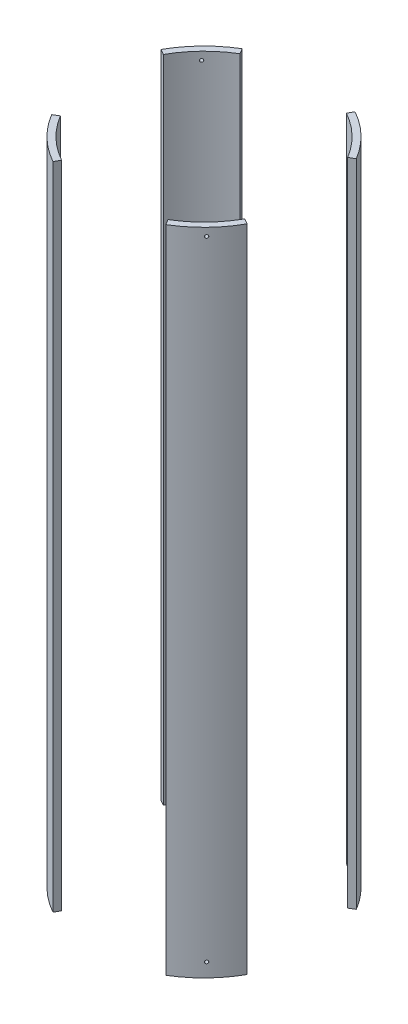
from build123d import *

# Parameters (mm, degrees)
SKETCH2_R               = 88.9
SKETCH2_R_2             = 83.82
BOSS_EXTRUDE1_DEPTH     = 260.20776
CUT_EXTRUDE1_DEPTH      = 261.20776
CUT_EXTRUDE1_DEPTH_BACK = 261.20776
SKETCH5_R               = 1.27
BOLT_HOLES_DEPTH        = 29.911624556
BOLT_PATTERN_COUNT      = 4


with BuildPart() as part:
    # Sketch2 → Boss-Extrude1 (new body, symmetric)
    with BuildSketch(Plane(origin=(0, 0, 0), x_dir=(1, 0, 0), z_dir=(0, 1, 0))):
        Circle(SKETCH2_R)
        Circle(SKETCH2_R_2, mode=Mode.SUBTRACT)
    extrude(amount=BOSS_EXTRUDE1_DEPTH, both=True)

    # Sketch3 → Cut-Extrude1 (cut, two sides)
    with BuildSketch(Plane(origin=(0, 0, 0), x_dir=(1, 0, 0), z_dir=(0, 1, 0))) as cut_extrude1_sk:
        Polygon((169.661755759, -94.300371224), (0, 0), (169.661755759, 101.677593364), align=None)
        Polygon((0, 0), (53.900027233, 96.974944394), (-58.116685864, 96.974944394), align=None)
        Polygon((-123.741299607, 68.777140945), (-123.741299607, -74.157652604), (0, 0), align=None)
        Polygon((-65.840936026, -118.45858783), (0, 0), (70.991745134, -118.45858783), align=None)
    extrude(amount=CUT_EXTRUDE1_DEPTH, mode=Mode.SUBTRACT)
    extrude(cut_extrude1_sk.sketch, amount=-CUT_EXTRUDE1_DEPTH_BACK, mode=Mode.SUBTRACT)

    # Sketch5 → Bolt holes (cut, through all)
    with BuildSketch(Plane(origin=(-56.309218645, 0, 58.175814955), x_dir=(-0.718540152, 0, -0.695485478), z_dir=(0.695485478, 0, -0.718540152))):
        with Locations((-0.02278764, 253.85776)):
            Circle(SKETCH5_R)
        with Locations((-0.02278764, -249.09526)):
            Circle(SKETCH5_R)
    bolt_holes = extrude(amount=-BOLT_HOLES_DEPTH, mode=Mode.SUBTRACT)

    # Bolt pattern: Bolt holes ×4 about axis
    bolt_pattern_axis = Axis((0, 260.20776, 0), (0, 1, 0))
    for i in range(1, BOLT_PATTERN_COUNT):
        add(bolt_holes.rotate(bolt_pattern_axis, i * 360 / BOLT_PATTERN_COUNT), mode=Mode.SUBTRACT)


solid = part.part
